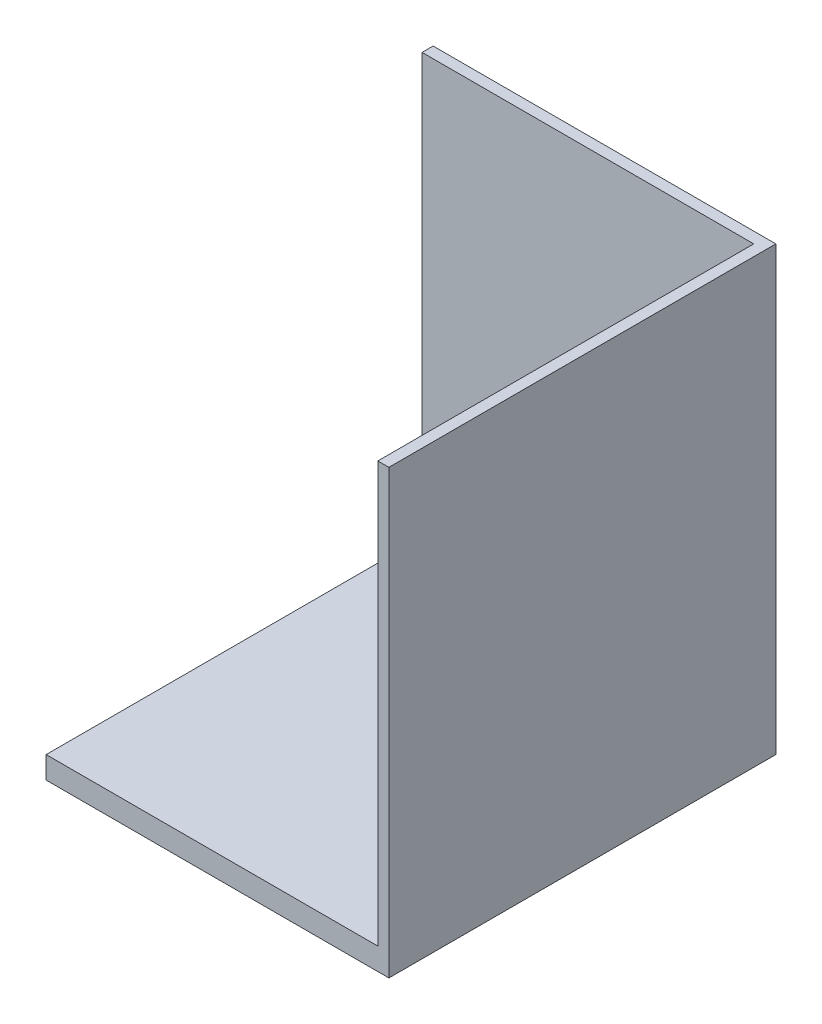
from build123d import *

# Parameters (mm, degrees)
SKETCH1_W               = 150
SKETCH1_H               = 10
BOSS_EXTRUDE1_DEPTH     = 200
BOSS_EXTRUDE2_DEPTH     = 205
SKETCH3_W               = 5
SKETCH3_H               = 300
BOSS_EXTRUDE3_DEPTH     = 150
BOSS_EXTRUDE4_DEPTH     = 30
CUT_EXTRUDE3_DEPTH      = 151
CUT_EXTRUDE3_DEPTH_BACK = 6


with BuildPart() as part:
    # Sketch1 → Boss-Extrude1 (new body)
    with BuildSketch(Plane.XY):
        with Locations((-9.782608696, -38.260869565)):
            Rectangle(SKETCH1_W, SKETCH1_H)
    extrude(amount=-BOSS_EXTRUDE1_DEPTH)

    # Sketch2 → Boss-Extrude2 (add)
    with BuildSketch(Plane.XY):
        Polygon((65.217391304, -43.260869565), (70.217391304, -43.260869565), (70.217391304, 256.739130435), (65.217391304, 256.739130435), (65.217391304, -33.260869565), align=None)
    extrude(amount=-BOSS_EXTRUDE2_DEPTH)

    # Sketch3 → Boss-Extrude3 (add)
    with BuildSketch(Plane.ZY.offset(84.782608696)):
        with Locations((-202.5, 106.739130435)):
            Rectangle(SKETCH3_W, SKETCH3_H)
    extrude(amount=-BOSS_EXTRUDE3_DEPTH)

    # Sketch4 → Boss-Extrude4 (add)
    with BuildSketch(Plane.XZ.offset(43.260869565)):
        Polygon((25.217391304, -160), (-84.782608696, -160), (-84.782608696, -170), (35.217391304, -170), (35.217391304, -60), (25.217391304, -60), align=None)
    extrude(amount=BOSS_EXTRUDE4_DEPTH)

    # Sketch5 → Cut-Extrude3 (cut, two sides)
    with BuildSketch(Plane.ZY.offset(-65.217391304)) as cut_extrude3_sk:
        Polygon((-205, 256.739130435), (-205, 156.739130435), (-30, 156.739130435), (-30, -73.260869565), (0, -73.260869565), (0, 256.739130435), align=None)
    extrude(amount=CUT_EXTRUDE3_DEPTH, mode=Mode.SUBTRACT)
    extrude(cut_extrude3_sk.sketch, amount=-CUT_EXTRUDE3_DEPTH_BACK, mode=Mode.SUBTRACT)


solid = part.part
